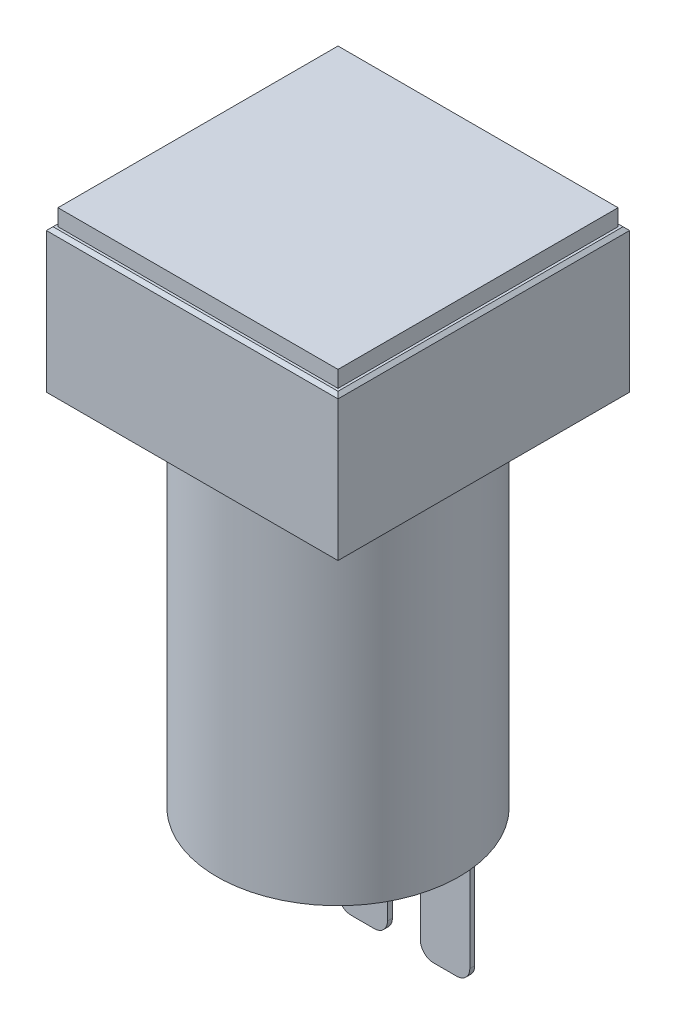
from build123d import *

# Parameters (mm, degrees)
SKETCH_1_W      = 17.7
SKETCH_1_H      = 17.7
EXTRUDE_1_DEPTH = 8.7
SKETCH_2_R      = 7.35
EXTRUDE_2_DEPTH = 21.8
SKETCH_3_W      = 3
SKETCH_3_H      = 0.3
EXTRUDE_3_DEPTH = 6.8
FILLET_1_R      = 0.8
SKETCH_4_W      = 17
SKETCH_4_H      = 17
EXTRUDE_4_DEPTH = 1
CHAMFER_1_SIZE  = 0.2


with BuildPart() as part:
    # 草图1 → 凸台-拉伸1 (new body)
    with BuildSketch(Plane(origin=(0, 0, 0), x_dir=(1, 0, 0), z_dir=(0, 1, 0))):
        Rectangle(SKETCH_1_W, SKETCH_1_H)
    extrude(amount=EXTRUDE_1_DEPTH)

    # 草图2 → 凸台-拉伸2 (add)
    with BuildSketch(Plane.XZ):
        Circle(SKETCH_2_R)
    extrude(amount=EXTRUDE_2_DEPTH)

    # 草图3 → 凸台-拉伸3 (add)
    with BuildSketch(Plane.XZ.offset(21.8)):
        with Locations((-5, -1.65)):
            Rectangle(SKETCH_3_W, SKETCH_3_H)
        with Locations((0, -1.65)):
            Rectangle(SKETCH_3_W, SKETCH_3_H)
        with Locations((5, -1.65)):
            Rectangle(SKETCH_3_W, SKETCH_3_H)
    extrude(amount=EXTRUDE_3_DEPTH)

    # 圆角1
    fillet_1_edges = [part.edges().sort_by_distance(p)[0] for p in [
        (-6.5, -28.6, -1.65),
        (-3.5, -28.6, -1.65),
        (-1.5, -28.6, -1.65),
        (1.5, -28.6, -1.65),
        (3.5, -28.6, -1.65),
        (6.5, -28.6, -1.65),
    ]]
    fillet(fillet_1_edges, radius=FILLET_1_R)

    # 草图4 → 凸台-拉伸4 (add)
    with BuildSketch(Plane(origin=(0, 8.7, 0), x_dir=(1, 0, 0), z_dir=(0, 1, 0))):
        Rectangle(SKETCH_4_W, SKETCH_4_H)
    extrude(amount=EXTRUDE_4_DEPTH)

    # 倒角1
    chamfer_1_edges = [part.edges().sort_by_distance(p)[0] for p in [
        (-8.85, 8.7, 0),
        (0, 8.7, 8.85),
        (8.85, 8.7, 0),
        (0, 8.7, -8.85),
    ]]
    chamfer(chamfer_1_edges, length=CHAMFER_1_SIZE)


solid = part.part
